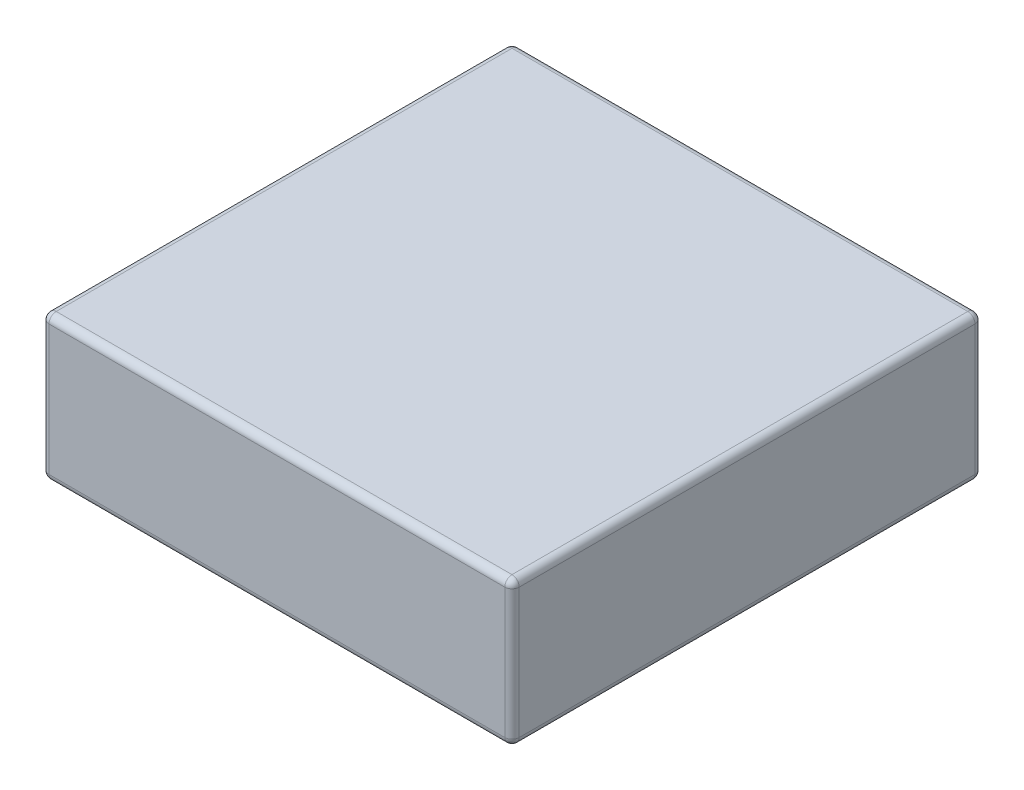
from build123d import *

# Parameters (mm, degrees)
SKETCH1_W           = 65
SKETCH1_H           = 65
BOSS_EXTRUDE1_DEPTH = 20
FILLET1_R           = 1
BOSS_EXTRUDE2_DEPTH = 2


with BuildPart() as part:
    # Sketch1 → Boss-Extrude1 (new body)
    with BuildSketch(Plane(origin=(0, 0, 0), x_dir=(1, 0, 0), z_dir=(0, 1, 0))):
        with Locations((32.5, 32.5)):
            Rectangle(SKETCH1_W, SKETCH1_H)
    extrude(amount=BOSS_EXTRUDE1_DEPTH)

    # Fillet1
    fillet1_edges = [part.edges().sort_by_distance(p)[0] for p in [
        (65, 20, -32.5),
        (32.5, 20, -65),
        (0, 20, -32.5),
        (32.5, 0, -65),
        (65, 0, -32.5),
        (32.5, 0, 0),
        (0, 0, -32.5),
        (0, 10, -65),
        (65, 10, -65),
        (65, 10, 0),
        (0, 10, 0),
        (32.5, 20, 0),
    ]]
    fillet(fillet1_edges, radius=FILLET1_R)

    # Sketch5 → Boss-Extrude2 (add)
    with BuildSketch(Plane(origin=(0, 20, 0), x_dir=(1, 0, 0), z_dir=(0, 1, 0))):
        Polygon((19.685637492, 45.314362508), (24.766822527, 50.395547542), (25.276108448, 49.886261621), (20.194923413, 44.805076587), align=None)
        with BuildLine():
            Line((24.270811136, 43.09904656), (24.718807634, 42.493448688))
            add(Edge.make_bspline(
                [(24.718807634, 42.493448688), (24.65944603, 42.457112102), (24.543657841, 42.386235522), (24.36613492, 42.296211036), (24.192297686, 42.219040325), (24.01995098, 42.159212632), (23.849730523, 42.114752837), (23.681690942, 42.086719988), (23.516089318, 42.075383185), (23.353313359, 42.077400194), (23.19429728, 42.097465643), (23.038449433, 42.128495622), (22.887328161, 42.177860051), (22.740286195, 42.240265036), (22.597438103, 42.3173153), (22.45826992, 42.40727332), (22.32545788, 42.515129055), (22.241429087, 42.594556655), (22.198644924, 42.63499807)],
                knots=[0, 0, 0, 0, 0.000208722, 0.000407124, 0.000596633, 0.000778925, 0.00095377, 0.001123861, 0.001289171, 0.001451177, 0.001611365, 0.001769344, 0.001927175, 0.002087363, 0.002247969, 0.002413511, 0.002583753, 0.002760349, 0.002760349, 0.002760349, 0.002760349], degree=3))
            add(Edge.make_bspline(
                [(22.198644924, 42.63499807), (22.147701284, 42.688346884), (22.04765429, 42.793117339), (21.922554095, 42.967231051), (21.817569235, 43.147019722), (21.73659792, 43.335189786), (21.679785512, 43.530848968), (21.644085884, 43.733421879), (21.633386128, 43.943953589), (21.643285872, 44.161113728), (21.677814894, 44.38377928), (21.742580127, 44.606907144), (21.828375675, 44.832560204), (21.944279573, 45.056953333), (22.083016879, 45.284675208), (22.25070644, 45.510705787), (22.440615653, 45.740739094), (22.58325937, 45.886785575), (22.656856326, 45.962138185)],
                knots=[0, 0, 0, 0, 0.000221059, 0.000434133, 0.00064138, 0.000844681, 0.001046936, 0.001251338, 0.00146034, 0.001678012, 0.001902569, 0.002134488, 0.002373782, 0.002625691, 0.002890982, 0.003172935, 0.003469264, 0.003785121, 0.003785121, 0.003785121, 0.003785121], degree=3))
            add(Edge.make_bspline(
                [(22.656856326, 45.962138185), (22.735304815, 46.037955999), (22.88748258, 46.185030666), (23.123303486, 46.384632603), (23.357638034, 46.557100392), (23.590677334, 46.702822596), (23.821840648, 46.822078206), (24.051852, 46.914709279), (24.280409589, 46.981983021), (24.506932694, 47.018796963), (24.727384439, 47.03431778), (24.940233058, 47.025482357), (25.144352505, 46.994971105), (25.340085808, 46.942519294), (25.526286742, 46.866215225), (25.702710621, 46.766561684), (25.872394562, 46.647715855), (25.973496188, 46.551133092), (26.024856056, 46.502068817)],
                knots=[0, 0, 0, 0, 0.000327232, 0.000634778, 0.000926067, 0.001199391, 0.001458489, 0.001705352, 0.00194228, 0.002171628, 0.00239246, 0.002604236, 0.002809376, 0.003010444, 0.003210705, 0.003411263, 0.003617372, 0.003830186, 0.003830186, 0.003830186, 0.003830186], degree=3))
            add(Edge.make_bspline(
                [(26.024856056, 46.502068817), (26.071398533, 46.453066353), (26.163167054, 46.356447435), (26.277023523, 46.193668973), (26.37086823, 46.023021925), (26.443461426, 45.842869536), (26.493233934, 45.653122307), (26.520175644, 45.45373442), (26.527595943, 45.24544748), (26.512535805, 45.029344415), (26.475308317, 44.807364737), (26.409425794, 44.583426164), (26.320915695, 44.357268318), (26.201043695, 44.132062546), (26.060507567, 43.902626648), (25.89079672, 43.673437755), (25.696655056, 43.442073581), (25.552080753, 43.293670825), (25.477629063, 43.21724759)],
                knots=[0, 0, 0, 0, 0.000202508, 0.000399288, 0.000593897, 0.000785751, 0.000980426, 0.001180814, 0.001388159, 0.001604624, 0.001829655, 0.002061973, 0.002303688, 0.00255693, 0.002826235, 0.003110228, 0.003411606, 0.003731589, 0.003731589, 0.003731589, 0.003731589], degree=3))
            Line((25.477629063, 43.21724759), (25.308353514, 43.053809128))
            Line((25.308353514, 43.053809128), (23.055237576, 45.306925066))
            add(Edge.make_bspline(
                [(23.055237576, 45.306925066), (23.008428941, 45.253428574), (22.917532008, 45.149544603), (22.794995519, 44.99005008), (22.687606361, 44.834345409), (22.598042408, 44.680102339), (22.523988968, 44.528378877), (22.46893383, 44.377973841), (22.428484602, 44.230679765), (22.404672414, 44.086328807), (22.398574981, 43.946465898), (22.401417614, 43.812435439), (22.421043899, 43.684765665), (22.452728022, 43.563194715), (22.498625025, 43.448182852), (22.557092061, 43.339791827), (22.629175623, 43.237817936), (22.686267844, 43.176729605), (22.715227205, 43.145743263)],
                knots=[0, 0, 0, 0, 0.000213204, 0.000414017, 0.000603036, 0.00078024, 0.000948633, 0.00110884, 0.001259993, 0.001406336, 0.001546616, 0.001679481, 0.001807848, 0.00193315, 0.002055633, 0.002178385, 0.002301882, 0.002429006, 0.002429006, 0.002429006, 0.002429006], degree=3))
            add(Edge.make_bspline(
                [(22.715227205, 43.145743263), (22.763714327, 43.101268255), (22.858414682, 43.014403973), (23.025956737, 42.922340751), (23.204141766, 42.861085255), (23.396323147, 42.841646968), (23.600048933, 42.851176309), (23.814991722, 42.901604999), (24.042730565, 42.981679607), (24.192378727, 43.05868638), (24.270811136, 43.09904656)],
                knots=[0, 0, 0, 0, 0.000196748, 0.000384268, 0.000568853, 0.000758368, 0.000960006, 0.001178117, 0.001418122, 0.001682448, 0.001682448, 0.001682448, 0.001682448], degree=3))
        make_face()
        with BuildLine():
            Line((23.598086753, 45.788484819), (25.282086618, 44.104484954))
            add(Edge.make_bspline(
                [(25.282086618, 44.104484954), (25.317456152, 44.146521608), (25.385900663, 44.227867836), (25.479775603, 44.350787831), (25.561877228, 44.470464632), (25.632124497, 44.587358235), (25.691145975, 44.700570312), (25.736058611, 44.811350606), (25.773087872, 44.917520401), (25.786377298, 44.989073722), (25.792831811, 45.023826301)],
                knots=[0, 0, 0, 0, 0.000164794, 0.000318898, 0.0004638, 0.000599943, 0.000727861, 0.000846287, 0.000958423, 0.001064318, 0.001064318, 0.001064318, 0.001064318], degree=3))
            add(Edge.make_bspline(
                [(25.792831811, 45.023826301), (25.799813725, 45.071878299), (25.813377134, 45.165226467), (25.814257222, 45.30339848), (25.801182934, 45.435020893), (25.774145727, 45.560903067), (25.729739188, 45.679965001), (25.670458197, 45.791928238), (25.597330146, 45.898165534), (25.538293331, 45.961856188), (25.508273775, 45.994242168)],
                knots=[0, 0, 0, 0, 0.000145525, 0.000282705, 0.000413242, 0.000541766, 0.000667814, 0.000793141, 0.000921059, 0.001053395, 0.001053395, 0.001053395, 0.001053395], degree=3))
            add(Edge.make_bspline(
                [(25.508273775, 45.994242168), (25.479202656, 46.021698757), (25.422234743, 46.075502829), (25.327077988, 46.143572618), (25.226022071, 46.198991516), (25.119469498, 46.243146809), (25.006665555, 46.273929901), (24.888728253, 46.292595438), (24.764604833, 46.299684032), (24.636059667, 46.29554037), (24.504591069, 46.27783771), (24.372662252, 46.247016845), (24.241600945, 46.202755032), (24.110298143, 46.147206738), (23.980677113, 46.076811617), (23.852388098, 45.992570612), (23.722553615, 45.897996438), (23.640333437, 45.825655378), (23.598086753, 45.788484819)],
                knots=[0, 0, 0, 0, 0.000119856, 0.00023487, 0.00034982, 0.000464991, 0.000580052, 0.000699766, 0.000822561, 0.00095251, 0.001085007, 0.001219869, 0.001358308, 0.001499526, 0.001647086, 0.001800087, 0.001959736, 0.002128463, 0.002128463, 0.002128463, 0.002128463], degree=3))
        make_face(mode=Mode.SUBTRACT)
        with BuildLine():
            Line((24.256928886, 40.743071114), (27.937212819, 44.423355048))
            Line((27.937212819, 44.423355048), (28.396883493, 43.963684374))
            Line((28.396883493, 43.963684374), (27.874464124, 43.441265005))
            add(Edge.make_bspline(
                [(27.874464124, 43.441265005), (27.950920243, 43.461674048), (28.098922361, 43.501181437), (28.321702162, 43.527286092), (28.534408586, 43.525711262), (28.736967661, 43.492266462), (28.930507375, 43.434748033), (29.112252205, 43.344942514), (29.285821773, 43.23105084), (29.388065649, 43.135461808), (29.440262959, 43.086661914)],
                knots=[0, 0, 0, 0, 0.00023714, 0.00045905, 0.000670664, 0.000873146, 0.001073023, 0.001274043, 0.001479241, 0.001693257, 0.001693257, 0.001693257, 0.001693257], degree=3))
            add(Edge.make_bspline(
                [(29.440262959, 43.086661914), (29.479237571, 43.045701744), (29.555948444, 42.965082845), (29.651727199, 42.830729926), (29.733688037, 42.691079746), (29.796795775, 42.54476151), (29.843933405, 42.396078746), (29.872725772, 42.248190754), (29.887408477, 42.10287992), (29.880498237, 41.958770633), (29.857841761, 41.814281782), (29.811728374, 41.668054182), (29.749403454, 41.518247208), (29.680906385, 41.391900736), (29.614240997, 41.286817058), (29.55205399, 41.200752274), (29.481461369, 41.107516401), (29.397994108, 41.009652562), (29.307522476, 40.903718375), (29.205603934, 40.792000351), (29.093727999, 40.674235372), (29.014326282, 40.594545181), (28.973295925, 40.553365757)],
                knots=[0, 0, 0, 0, 0.000169426, 0.00033347, 0.000493658, 0.000654423, 0.000810422, 0.00096067, 0.001105734, 0.001247403, 0.001392305, 0.001543261, 0.001706138, 0.001878505, 0.001973638, 0.002079322, 0.002196945, 0.00232437, 0.002465082, 0.002614877, 0.002777963, 0.00295235, 0.00295235, 0.00295235, 0.00295235], degree=3))
            Line((28.973295925, 40.553365757), (26.709965084, 38.290034916))
            Line((26.709965084, 38.290034916), (26.197760619, 38.802239381))
            Line((26.197760619, 38.802239381), (28.436283837, 41.040762598))
            add(Edge.make_bspline(
                [(28.436283837, 41.040762598), (28.498834303, 41.104732657), (28.614954251, 41.223487965), (28.764812047, 41.398480511), (28.879101321, 41.554577542), (28.960654173, 41.695654959), (29.012514868, 41.828209488), (29.040075072, 41.956841821), (29.050277675, 42.084305362), (29.036279506, 42.209999528), (29.003709911, 42.331703897), (28.954677983, 42.448518613), (28.882691104, 42.556276666), (28.823880395, 42.620443943), (28.793805472, 42.653258136)],
                knots=[0, 0, 0, 0, 0.000268355, 0.00049818, 0.00069055, 0.000848023, 0.00098569, 0.001115639, 0.001241442, 0.001367624, 0.001492926, 0.001618432, 0.001745925, 0.001879358, 0.001879358, 0.001879358, 0.001879358], degree=3))
            add(Edge.make_bspline(
                [(28.793805472, 42.653258136), (28.763187059, 42.682046242), (28.702932566, 42.738698845), (28.605315182, 42.81236554), (28.502003168, 42.870205812), (28.396735111, 42.918527741), (28.285997777, 42.950250802), (28.171905723, 42.969342191), (28.053919522, 42.97490495), (27.931901325, 42.967925543), (27.804732482, 42.94415941), (27.673021679, 42.901129229), (27.536350163, 42.838100954), (27.393143948, 42.75815232), (27.246606826, 42.656239788), (27.093618898, 42.536931702), (26.935494109, 42.398840319), (26.83109022, 42.297220606), (26.777091595, 42.244661982)],
                knots=[0, 0, 0, 0, 0.000126039, 0.000248035, 0.000365685, 0.000480662, 0.000594719, 0.000710112, 0.000827, 0.000948339, 0.00107599, 0.001213974, 0.001362884, 0.001526876, 0.001705373, 0.001897736, 0.002108731, 0.002334768, 0.002334768, 0.002334768, 0.002334768], degree=3))
            Line((26.777091595, 42.244661982), (24.766214807, 40.233785193))
            Line((24.766214807, 40.233785193), (24.256928886, 40.743071114))
        make_face()
        with BuildLine():
            Line((28.397593963, 38.800069639), (28.998814018, 38.391473485))
            add(Edge.make_bspline(
                [(28.998814018, 38.391473485), (28.971522035, 38.355862259), (28.918530346, 38.286717449), (28.850053452, 38.179416628), (28.791547054, 38.074906972), (28.743199129, 37.971463994), (28.709297745, 37.868277663), (28.683201074, 37.767042009), (28.670469797, 37.667078287), (28.666043136, 37.536705125), (28.688594893, 37.374482586), (28.758670326, 37.187340011), (28.866105164, 37.006369777), (28.964064917, 36.900834271), (29.01486601, 36.846104458)],
                knots=[0, 0, 0, 0, 0.000134546, 0.000261243, 0.000381436, 0.000493752, 0.00060312, 0.00070682, 0.000806916, 0.000904731, 0.001097692, 0.00129343, 0.001500898, 0.001724391, 0.001724391, 0.001724391, 0.001724391], degree=3))
            add(Edge.make_bspline(
                [(29.01486601, 36.846104458), (29.069441835, 36.795835111), (29.172990452, 36.700457326), (29.342679441, 36.588820454), (29.516720057, 36.519990136), (29.690805894, 36.489543092), (29.859716906, 36.498403237), (30.01876995, 36.541915162), (30.16708271, 36.618757165), (30.250415812, 36.693776173), (30.293188265, 36.732281244)],
                knots=[0, 0, 0, 0, 0.000222389, 0.000421947, 0.000605404, 0.000780054, 0.000948098, 0.001108466, 0.00127165, 0.001443733, 0.001443733, 0.001443733, 0.001443733], degree=3))
            add(Edge.make_bspline(
                [(30.293188265, 36.732281244), (30.326160082, 36.768383514), (30.389471047, 36.83770543), (30.452583476, 36.961547014), (30.483616436, 37.093216642), (30.478287487, 37.18210217), (30.475597262, 37.226974445)],
                knots=[0, 0, 0, 0, 0.000146109, 0.000280553, 0.000412243, 0.000546504, 0.000546504, 0.000546504, 0.000546504], degree=3))
            add(Edge.make_bspline(
                [(30.475597262, 37.226974445), (30.472436749, 37.244538199), (30.465345915, 37.283943725), (30.447476422, 37.347936753), (30.420458765, 37.422708398), (30.385593212, 37.508478052), (30.341249593, 37.604367281), (30.290137516, 37.711619684), (30.229915462, 37.829400163), (30.187187713, 37.911880955), (30.164772331, 37.955151163)],
                knots=[0, 0, 0, 0, 5.3518e-05, 0.000120071, 0.000198993, 0.000291941, 0.000397735, 0.000515873, 0.000648354, 0.000794551, 0.000794551, 0.000794551, 0.000794551], degree=3))
            add(Edge.make_bspline(
                [(30.164772331, 37.955151163), (30.132090575, 38.017850384), (30.069445542, 38.138033488), (29.980891546, 38.311481042), (29.906007385, 38.472488345), (29.838085929, 38.617626828), (29.782172165, 38.748899705), (29.738643504, 38.866657164), (29.702585494, 38.969246159), (29.671389798, 39.087584192), (29.651000577, 39.227233321), (29.645328094, 39.392084984), (29.66561401, 39.556940667), (29.706464713, 39.720228472), (29.768908951, 39.881076669), (29.855399766, 40.034931713), (29.960088954, 40.184138289), (30.045337829, 40.273512063), (30.088890188, 40.31917177)],
                knots=[0, 0, 0, 0, 0.000212122, 0.0004066, 0.000584152, 0.000744778, 0.000887339, 0.001012019, 0.001121387, 0.001213414, 0.001378724, 0.00154368, 0.001706766, 0.001875235, 0.002047583, 0.002222629, 0.002403632, 0.002592691, 0.002592691, 0.002592691, 0.002592691], degree=3))
            add(Edge.make_bspline(
                [(30.088890188, 40.31917177), (30.128032615, 40.356994116), (30.204637433, 40.431015431), (30.329853162, 40.525425421), (30.457257226, 40.606915946), (30.589343694, 40.672832991), (30.725094725, 40.72443303), (30.865240049, 40.759511449), (31.009011182, 40.779880625), (31.15574204, 40.785985308), (31.303476447, 40.77552129), (31.450575101, 40.749648993), (31.595190228, 40.704455907), (31.739136944, 40.646670282), (31.880006672, 40.570079835), (32.016772837, 40.474711543), (32.155421954, 40.367907691), (32.241136901, 40.284569229), (32.285094518, 40.241830356)],
                knots=[0, 0, 0, 0, 0.000163152, 0.0003193, 0.000469499, 0.000616336, 0.000761341, 0.000904327, 0.001048787, 0.001196289, 0.001344029, 0.001492302, 0.001643257, 0.00179772, 0.001957041, 0.002122988, 0.002297565, 0.00248134, 0.00248134, 0.00248134, 0.00248134], degree=3))
            add(Edge.make_bspline(
                [(32.285094518, 40.241830356), (32.337852306, 40.185948728), (32.440535985, 40.077185051), (32.571187106, 39.900500906), (32.677552367, 39.719402205), (32.756128791, 39.533579644), (32.810566231, 39.348425774), (32.840497313, 39.166043217), (32.845606599, 38.987690971), (32.823451513, 38.810732341), (32.769345652, 38.630694319), (32.684733386, 38.442518618), (32.568144059, 38.242589122), (32.471765986, 38.111840057), (32.420806812, 38.042707482)],
                knots=[0, 0, 0, 0, 0.000230385, 0.000448403, 0.000657645, 0.000859029, 0.001052062, 0.00123535, 0.001411976, 0.001585556, 0.001767965, 0.001973769, 0.002203283, 0.002460794, 0.002460794, 0.002460794, 0.002460794], degree=3))
            Line((32.420806812, 38.042707482), (31.838557292, 38.458599996))
            add(Edge.make_bspline(
                [(31.838557292, 38.458599996), (31.879401728, 38.51282359), (31.956839937, 38.615627749), (32.038231596, 38.782456396), (32.088056737, 38.946173696), (32.097929335, 39.108657145), (32.074764551, 39.268501518), (32.011217909, 39.423461233), (31.917510187, 39.578116516), (31.831252687, 39.668893474), (31.7860235, 39.716492443)],
                knots=[0, 0, 0, 0, 0.000203232, 0.000385314, 0.00055389, 0.000713278, 0.000869713, 0.001034204, 0.001212402, 0.001408846, 0.001408846, 0.001408846, 0.001408846], degree=3))
            add(Edge.make_bspline(
                [(31.7860235, 39.716492443), (31.732905563, 39.767245769), (31.632896426, 39.862802875), (31.471323107, 39.973278235), (31.314661986, 40.048901469), (31.161343523, 40.083293574), (31.016122049, 40.084183944), (30.881109182, 40.052442759), (30.756185721, 39.992096689), (30.687338587, 39.930412026), (30.652169172, 39.89890144)],
                knots=[0, 0, 0, 0, 0.000220079, 0.00041436, 0.00058477, 0.000738777, 0.000881786, 0.001016648, 0.001151739, 0.001292814, 0.001292814, 0.001292814, 0.001292814], degree=3))
            add(Edge.make_bspline(
                [(30.652169172, 39.89890144), (30.620980875, 39.864787494), (30.56085833, 39.799025094), (30.505240554, 39.679362067), (30.475944511, 39.552357767), (30.483423349, 39.466101156), (30.487271438, 39.421719503)],
                knots=[0, 0, 0, 0, 0.000137892, 0.000265817, 0.000391179, 0.000524045, 0.000524045, 0.000524045, 0.000524045], degree=3))
            add(Edge.make_bspline(
                [(30.487271438, 39.421719503), (30.490395657, 39.405599282), (30.497591674, 39.368469557), (30.51761967, 39.306581144), (30.547778094, 39.231420948), (30.583137156, 39.140516056), (30.631435245, 39.037519127), (30.684545951, 38.91846373), (30.749096811, 38.786514203), (30.795575431, 38.693983064), (30.81998545, 38.645386809)],
                knots=[0, 0, 0, 0, 4.9227e-05, 0.000113386, 0.000194687, 0.00029224, 0.000405885, 0.000535834, 0.000683336, 0.000846488, 0.000846488, 0.000846488, 0.000846488], degree=3))
            add(Edge.make_bspline(
                [(30.81998545, 38.645386809), (30.854241274, 38.578364373), (30.919783653, 38.450128957), (31.010409734, 38.264835791), (31.088680835, 38.096258791), (31.156781293, 37.94468116), (31.213492505, 37.810005253), (31.259398025, 37.691477566), (31.293388142, 37.589773918), (31.322924098, 37.476840305), (31.342727876, 37.346038471), (31.346133978, 37.190906285), (31.326672281, 37.0352135), (31.285351421, 36.879683127), (31.221973226, 36.725730455), (31.136256285, 36.574338558), (31.027588952, 36.425818198), (30.94073455, 36.334418329), (30.895867593, 36.28720329)],
                knots=[0, 0, 0, 0, 0.000225806, 0.000432038, 0.000618757, 0.00078337, 0.000930533, 0.001057094, 0.001164616, 0.001252039, 0.001407031, 0.001560282, 0.001716124, 0.001876112, 0.002041687, 0.002214184, 0.002396896, 0.002592139, 0.002592139, 0.002592139, 0.002592139], degree=3))
            add(Edge.make_bspline(
                [(30.895867593, 36.28720329), (30.851817853, 36.245074856), (30.765912472, 36.162916386), (30.627629082, 36.055078362), (30.484151508, 35.966369126), (30.337376295, 35.892498955), (30.186503854, 35.834808362), (30.030651537, 35.79571987), (29.870826238, 35.771824325), (29.707857867, 35.766324916), (29.544441736, 35.777811936), (29.382528905, 35.807402037), (29.223111606, 35.854369959), (29.065755909, 35.918731104), (28.912773946, 36.003128348), (28.761056762, 36.103050362), (28.612124467, 36.221279404), (28.518484897, 36.311216194), (28.470557562, 36.357248345)],
                knots=[0, 0, 0, 0, 0.000182782, 0.00035646, 0.00052491, 0.000688061, 0.00084878, 0.001008402, 0.001169167, 0.00133271, 0.001496565, 0.001659716, 0.00182549, 0.001994318, 0.002168663, 0.002348769, 0.002538839, 0.002738119, 0.002738119, 0.002738119, 0.002738119], degree=3))
            add(Edge.make_bspline(
                [(28.470557562, 36.357248345), (28.427696267, 36.402468293), (28.343913067, 36.490862078), (28.230344781, 36.628742225), (28.137296187, 36.771840292), (28.057674052, 36.91473211), (27.993735635, 37.059955561), (27.948727467, 37.208502847), (27.91867848, 37.359049844), (27.908110126, 37.511824801), (27.910033188, 37.666380447), (27.931374691, 37.822782558), (27.968283906, 37.981457637), (28.021195898, 38.142021663), (28.089925891, 38.304855974), (28.177404962, 38.468379919), (28.279416872, 38.635292974), (28.357473233, 38.744128509), (28.397593963, 38.800069639)],
                knots=[0, 0, 0, 0, 0.000186906, 0.000365356, 0.000534939, 0.000698221, 0.000855728, 0.001009901, 0.001163013, 0.001315226, 0.001468477, 0.00162595, 0.001787719, 0.001956616, 0.002132518, 0.002317247, 0.002512462, 0.002718922, 0.002718922, 0.002718922, 0.002718922], degree=3))
        make_face()
        with BuildLine():
            Line((32.194011935, 32.805988065), (35.389817571, 36.001793702))
            Line((35.389817571, 36.001793702), (34.935983985, 36.455627287))
            Line((34.935983985, 36.455627287), (35.420462283, 36.940105585))
            Line((35.420462283, 36.940105585), (35.874295868, 36.486271999))
            Line((35.874295868, 36.486271999), (36.266840031, 36.878816162))
            add(Edge.make_bspline(
                [(36.266840031, 36.878816162), (36.335517636, 36.945443651), (36.46397807, 37.070069373), (36.656925909, 37.230565412), (36.833848513, 37.353613251), (36.999247715, 37.439264272), (37.156364433, 37.492449427), (37.310202624, 37.517178985), (37.462874394, 37.519330465), (37.614658158, 37.495309962), (37.765426607, 37.446344255), (37.913452379, 37.370979935), (38.058218961, 37.268451948), (38.146891462, 37.184969378), (38.193079045, 37.141485118)],
                knots=[0, 0, 0, 0, 0.000286976, 0.000536785, 0.00075211, 0.000932234, 0.001093746, 0.001247524, 0.001397836, 0.001549944, 0.001706386, 0.001871497, 0.002046396, 0.002236539, 0.002236539, 0.002236539, 0.002236539], degree=3))
            add(Edge.make_bspline(
                [(38.193079045, 37.141485118), (38.229731778, 37.103635711), (38.305147448, 37.025757799), (38.408411527, 36.894542479), (38.513431492, 36.753923442), (38.576634578, 36.652160706), (38.608971559, 36.600095213)],
                knots=[0, 0, 0, 0, 0.000157959, 0.000325012, 0.000500429, 0.000684204, 0.000684204, 0.000684204, 0.000684204], degree=3))
            Line((38.608971559, 36.600095213), (37.99024024, 36.13312818))
            add(Edge.make_bspline(
                [(37.99024024, 36.13312818), (37.94856809, 36.19474545), (37.868033833, 36.313825004), (37.769353, 36.418330984), (37.721734195, 36.468760735)],
                knots=[0, 0, 0, 0, 0.000222734, 0.000430448, 0.000430448, 0.000430448, 0.000430448], degree=3))
            add(Edge.make_bspline(
                [(37.721734195, 36.468760735), (37.684984469, 36.503325988), (37.616380818, 36.567851707), (37.501351347, 36.6373372), (37.38710354, 36.676508314), (37.269527367, 36.681322992), (37.146066829, 36.648969031), (37.015877585, 36.572935867), (36.868735235, 36.464180863), (36.773005584, 36.370905363), (36.720673617, 36.319914993)],
                knots=[0, 0, 0, 0, 0.000151005, 0.000281893, 0.00040003, 0.000509563, 0.000629898, 0.000777458, 0.000958995, 0.001177905, 0.001177905, 0.001177905, 0.001177905], degree=3))
            Line((36.720673617, 36.319914993), (36.380663246, 35.979904622))
            Line((36.380663246, 35.979904622), (36.970209125, 35.390358742))
            Line((36.970209125, 35.390358742), (36.485730828, 34.905880445))
            Line((36.485730828, 34.905880445), (35.896184948, 35.495426324))
            Line((35.896184948, 35.495426324), (32.700379312, 32.299620688))
            Line((32.700379312, 32.299620688), (32.194011935, 32.805988065))
        make_face()
        Polygon((38.063745009, 35.662701431), (38.781706824, 36.380663246), (39.290992745, 35.871377324), (38.57303093, 35.15341551), align=None)
        Polygon((33.700521789, 31.299478211), (37.380805723, 34.979762145), (37.890091644, 34.470476224), (34.20980771, 30.79019229), align=None)
        Polygon((35.006711293, 29.993288707), (40.087896328, 35.074473741), (40.597182249, 34.56518782), (35.515997215, 29.484002785), align=None)
        with BuildLine():
            Line((38.03921955, 28.075664242), (37.557659797, 27.456932923))
            add(Edge.make_bspline(
                [(37.557659797, 27.456932923), (37.515050023, 27.482745795), (37.43238392, 27.532824672), (37.31718147, 27.612941746), (37.213488023, 27.695009592), (37.151582133, 27.75368446), (37.121337475, 27.782350574)],
                knots=[0, 0, 0, 0, 0.000149424, 0.000289894, 0.000420708, 0.00054567, 0.00054567, 0.00054567, 0.00054567], degree=3))
            add(Edge.make_bspline(
                [(37.121337475, 27.782350574), (37.080520821, 27.826284363), (37.00266627, 27.910084602), (36.905335621, 28.043375934), (36.837471953, 28.179367766), (36.793839433, 28.314754345), (36.776062632, 28.449207905), (36.781793895, 28.580641418), (36.810848404, 28.708565298), (36.851754189, 28.814304299), (36.903226494, 28.900217385), (36.952401532, 28.97672984), (37.017456151, 29.060621154), (37.095235374, 29.154191678), (37.185990582, 29.257605167), (37.289197155, 29.371823644), (37.408036732, 29.493393567), (37.491018667, 29.578231476), (37.534311445, 29.622492541)],
                knots=[0, 0, 0, 0, 0.00017984, 0.000343031, 0.00049313, 0.000633895, 0.000767839, 0.000897845, 0.001026369, 0.001159962, 0.001235802, 0.001326465, 0.001432701, 0.001553961, 0.001691513, 0.00184543, 0.002015715, 0.002201461, 0.002201461, 0.002201461, 0.002201461], degree=3))
            Line((37.534311445, 29.622492541), (39.651715088, 31.739896184))
            Line((39.651715088, 31.739896184), (39.276682189, 32.114929083))
            Line((39.276682189, 32.114929083), (39.761160487, 32.599407381))
            Line((39.761160487, 32.599407381), (40.136193386, 32.224374482))
            Line((40.136193386, 32.224374482), (41.048238373, 33.136419469))
            Line((41.048238373, 33.136419469), (41.931097921, 33.000707175))
            Line((41.931097921, 33.000707175), (40.645479307, 31.715088561))
            Line((40.645479307, 31.715088561), (41.162061588, 31.19850628))
            Line((41.162061588, 31.19850628), (40.67758329, 30.714027982))
            Line((40.67758329, 30.714027982), (40.161001009, 31.230610263))
            Line((40.161001009, 31.230610263), (38.008574839, 29.078184093))
            add(Edge.make_bspline(
                [(38.008574839, 29.078184093), (37.963565468, 29.032602902), (37.882150668, 28.950153768), (37.782632017, 28.831135525), (37.70657419, 28.737041742), (37.67976807, 28.67403323), (37.668564467, 28.647698859)],
                knots=[0, 0, 0, 0, 0.000191971, 0.000347244, 0.000466334, 0.000551848, 0.000551848, 0.000551848, 0.000551848], degree=3))
            add(Edge.make_bspline(
                [(37.668564467, 28.647698859), (37.661368448, 28.616170398), (37.647174638, 28.553981992), (37.667335502, 28.456091259), (37.713318119, 28.360307296), (37.764109452, 28.305966729), (37.791143314, 28.277043776)],
                knots=[0, 0, 0, 0, 9.5969e-05, 0.000189294, 0.000293066, 0.00041115, 0.00041115, 0.00041115, 0.00041115], degree=3))
            add(Edge.make_bspline(
                [(37.791143314, 28.277043776), (37.825644347, 28.245276519), (37.904125739, 28.173013796), (37.99070257, 28.110625921), (38.03921955, 28.075664242)],
                knots=[0, 0, 0, 0, 0.000140576, 0.000319775, 0.000319775, 0.000319775, 0.000319775], degree=3))
        make_face()
        with BuildLine():
            Line((41.242862717, 26.126994978), (41.690859215, 25.521397106))
            add(Edge.make_bspline(
                [(41.690859215, 25.521397106), (41.631497611, 25.485060521), (41.515709422, 25.414183941), (41.338186502, 25.324159455), (41.164349268, 25.246988743), (40.992002561, 25.18716105), (40.821782105, 25.142701255), (40.653742523, 25.114668406), (40.4881409, 25.103331603), (40.32536494, 25.105348613), (40.166348862, 25.125414061), (40.010501015, 25.156444041), (39.859379743, 25.20580847), (39.712337777, 25.268213455), (39.569489684, 25.345263718), (39.430321501, 25.435221738), (39.297509461, 25.543077474), (39.213480668, 25.622505073), (39.170696506, 25.662946489)],
                knots=[0, 0, 0, 0, 0.000208722, 0.000407124, 0.000596633, 0.000778925, 0.00095377, 0.001123861, 0.001289171, 0.001451177, 0.001611365, 0.001769344, 0.001927175, 0.002087363, 0.002247969, 0.002413511, 0.002583753, 0.002760349, 0.002760349, 0.002760349, 0.002760349], degree=3))
            add(Edge.make_bspline(
                [(39.170696506, 25.662946489), (39.119752865, 25.716295302), (39.019705871, 25.821065758), (38.894605676, 25.99517947), (38.789620817, 26.17496814), (38.708649501, 26.363138204), (38.651837093, 26.558797387), (38.616137466, 26.761370297), (38.605437709, 26.971902007), (38.615337453, 27.189062146), (38.649866476, 27.411727698), (38.714631708, 27.634855562), (38.800427257, 27.860508623), (38.916331154, 28.084901752), (39.055068461, 28.312623626), (39.222758022, 28.538654205), (39.412667234, 28.768687513), (39.555310952, 28.914733994), (39.628907907, 28.990086603)],
                knots=[0, 0, 0, 0, 0.000221059, 0.000434133, 0.00064138, 0.000844681, 0.001046936, 0.001251338, 0.00146034, 0.001678012, 0.001902569, 0.002134488, 0.002373782, 0.002625691, 0.002890982, 0.003172935, 0.003469264, 0.003785121, 0.003785121, 0.003785121, 0.003785121], degree=3))
            add(Edge.make_bspline(
                [(39.628907907, 28.990086603), (39.707356397, 29.065904417), (39.859534162, 29.212979085), (40.095355068, 29.412581022), (40.329689615, 29.58504881), (40.562728915, 29.730771014), (40.793892229, 29.850026625), (41.023903582, 29.942657697), (41.252461171, 30.00993144), (41.478984276, 30.046745381), (41.69943602, 30.062266198), (41.91228464, 30.053430775), (42.116404087, 30.022919524), (42.312137389, 29.970467712), (42.498338323, 29.894163644), (42.674762203, 29.794510102), (42.844446144, 29.675664273), (42.94554777, 29.57908151), (42.996907637, 29.530017236)],
                knots=[0, 0, 0, 0, 0.000327232, 0.000634778, 0.000926067, 0.001199391, 0.001458489, 0.001705352, 0.00194228, 0.002171628, 0.00239246, 0.002604236, 0.002809376, 0.003010444, 0.003210705, 0.003411263, 0.003617372, 0.003830186, 0.003830186, 0.003830186, 0.003830186], degree=3))
            add(Edge.make_bspline(
                [(42.996907637, 29.530017236), (43.043450114, 29.481014771), (43.135218636, 29.384395854), (43.249075105, 29.221617392), (43.342919812, 29.050970344), (43.415513007, 28.870817954), (43.465285516, 28.681070726), (43.492227225, 28.481682839), (43.499647524, 28.273395898), (43.484587386, 28.057292834), (43.447359898, 27.835313155), (43.381477375, 27.611374582), (43.292967277, 27.385216736), (43.173095277, 27.160010965), (43.032559148, 26.930575066), (42.862848302, 26.701386173), (42.668706637, 26.470022), (42.524132335, 26.321619244), (42.449680645, 26.245196009)],
                knots=[0, 0, 0, 0, 0.000202508, 0.000399288, 0.000593897, 0.000785751, 0.000980426, 0.001180814, 0.001388159, 0.001604624, 0.001829655, 0.002061973, 0.002303688, 0.00255693, 0.002826235, 0.003110228, 0.003411606, 0.003731589, 0.003731589, 0.003731589, 0.003731589], degree=3))
            Line((42.449680645, 26.245196009), (42.280405095, 26.081757547))
            Line((42.280405095, 26.081757547), (40.027289158, 28.334873484))
            add(Edge.make_bspline(
                [(40.027289158, 28.334873484), (39.980480522, 28.281376993), (39.889583589, 28.177493021), (39.767047101, 28.017998498), (39.659657943, 27.862293828), (39.570093989, 27.708050757), (39.496040549, 27.556327295), (39.440985411, 27.40592226), (39.400536183, 27.258628183), (39.376723995, 27.114277225), (39.370626562, 26.974414317), (39.373469195, 26.840383858), (39.393095481, 26.712714084), (39.424779604, 26.591143133), (39.470676606, 26.47613127), (39.529143643, 26.367740245), (39.601227205, 26.265766354), (39.658319425, 26.204678024), (39.687278787, 26.173691682)],
                knots=[0, 0, 0, 0, 0.000213204, 0.000414017, 0.000603036, 0.00078024, 0.000948633, 0.00110884, 0.001259993, 0.001406336, 0.001546616, 0.001679481, 0.001807848, 0.00193315, 0.002055633, 0.002178385, 0.002301882, 0.002429006, 0.002429006, 0.002429006, 0.002429006], degree=3))
            add(Edge.make_bspline(
                [(39.687278787, 26.173691682), (39.735765909, 26.129216673), (39.830466263, 26.042352392), (39.998008318, 25.950289169), (40.176193347, 25.889033673), (40.368374729, 25.869595386), (40.572100515, 25.879124727), (40.787043303, 25.929553417), (41.014782146, 26.009628025), (41.164430309, 26.086634798), (41.242862717, 26.126994978)],
                knots=[0, 0, 0, 0, 0.000196748, 0.000384268, 0.000568853, 0.000758368, 0.000960006, 0.001178117, 0.001418122, 0.001682448, 0.001682448, 0.001682448, 0.001682448], degree=3))
        make_face()
        with BuildLine():
            Line((40.570138335, 28.816433237), (42.2541382, 27.132433372))
            add(Edge.make_bspline(
                [(42.2541382, 27.132433372), (42.289507734, 27.174470026), (42.357952245, 27.255816254), (42.451827184, 27.37873625), (42.53392881, 27.49841305), (42.604176078, 27.615306653), (42.663197557, 27.728518731), (42.708110193, 27.839299025), (42.745139454, 27.945468819), (42.75842888, 28.01702214), (42.764883393, 28.05177472)],
                knots=[0, 0, 0, 0, 0.000164794, 0.000318898, 0.0004638, 0.000599943, 0.000727861, 0.000846287, 0.000958423, 0.001064318, 0.001064318, 0.001064318, 0.001064318], degree=3))
            add(Edge.make_bspline(
                [(42.764883393, 28.05177472), (42.771865307, 28.099826718), (42.785428716, 28.193174886), (42.786308804, 28.331346899), (42.773234516, 28.462969311), (42.746197308, 28.588851486), (42.701790769, 28.707913419), (42.642509779, 28.819876656), (42.569381728, 28.926113952), (42.510344912, 28.989804606), (42.480325356, 29.022190587)],
                knots=[0, 0, 0, 0, 0.000145525, 0.000282705, 0.000413242, 0.000541766, 0.000667814, 0.000793141, 0.000921059, 0.001053395, 0.001053395, 0.001053395, 0.001053395], degree=3))
            add(Edge.make_bspline(
                [(42.480325356, 29.022190587), (42.451254238, 29.049647175), (42.394286324, 29.103451247), (42.299129569, 29.171521037), (42.198073652, 29.226939935), (42.091521079, 29.271095227), (41.978717137, 29.30187832), (41.860779835, 29.320543856), (41.736656414, 29.327632451), (41.608111249, 29.323488788), (41.476642651, 29.305786129), (41.344713834, 29.274965264), (41.213652526, 29.23070345), (41.082349725, 29.175155156), (40.952728694, 29.104760036), (40.824439679, 29.020519031), (40.694605197, 28.925944857), (40.612385019, 28.853603796), (40.570138335, 28.816433237)],
                knots=[0, 0, 0, 0, 0.000119856, 0.00023487, 0.00034982, 0.000464991, 0.000580052, 0.000699766, 0.000822561, 0.00095251, 0.001085007, 0.001219869, 0.001358308, 0.001499526, 0.001647086, 0.001800087, 0.001959736, 0.002128463, 0.002128463, 0.002128463, 0.002128463], degree=3))
        make_face(mode=Mode.SUBTRACT)
        with BuildLine():
            Line((41.228980467, 23.771019533), (44.909264401, 27.451303466))
            Line((44.909264401, 27.451303466), (45.368935075, 26.991632793))
            Line((45.368935075, 26.991632793), (44.811493178, 26.434190896))
            add(Edge.make_bspline(
                [(44.811493178, 26.434190896), (44.857082737, 26.451115446), (44.944355433, 26.483514336), (45.072731118, 26.524238854), (45.191321051, 26.559222199), (45.300583308, 26.587819531), (45.401186409, 26.606480476), (45.49213213, 26.620156307), (45.574594504, 26.626514217), (45.670637516, 26.624677799), (45.780727504, 26.607602907), (45.902359417, 26.566479099), (46.013289455, 26.504444979), (46.075711452, 26.448123603), (46.107326697, 26.419598177)],
                knots=[0, 0, 0, 0, 0.000145869, 0.000279239, 0.000403919, 0.000516822, 0.000617849, 0.000710717, 0.000792644, 0.000865622, 0.000998536, 0.00112498, 0.001249147, 0.001376573, 0.001376573, 0.001376573, 0.001376573], degree=3))
            add(Edge.make_bspline(
                [(46.107326697, 26.419598177), (46.148139175, 26.373803537), (46.231671259, 26.280074316), (46.324052431, 26.107953941), (46.393464896, 25.911432893), (46.418311138, 25.769770819), (46.431285076, 25.695799274)],
                knots=[0, 0, 0, 0, 0.00018348, 0.000375534, 0.000581379, 0.000806325, 0.000806325, 0.000806325, 0.000806325], degree=3))
            Line((46.431285076, 25.695799274), (45.678300734, 25.290121664))
            add(Edge.make_bspline(
                [(45.678300734, 25.290121664), (45.66813895, 25.341626701), (45.648602219, 25.440648688), (45.596048332, 25.577070099), (45.532250791, 25.699036956), (45.47255771, 25.764477714), (45.443357946, 25.796489041)],
                knots=[0, 0, 0, 0, 0.000157175, 0.00030218, 0.000437397, 0.000566878, 0.000566878, 0.000566878, 0.000566878], degree=3))
            add(Edge.make_bspline(
                [(45.443357946, 25.796489041), (45.415027761, 25.821935808), (45.35875788, 25.872478597), (45.258936831, 25.928441543), (45.148478619, 25.965180092), (45.029197899, 25.983492882), (44.903427196, 25.984167173), (44.775563704, 25.961021756), (44.645965423, 25.91833137), (44.5638069, 25.87464899), (44.521098054, 25.851941376)],
                knots=[0, 0, 0, 0, 0.000113973, 0.000226375, 0.000340357, 0.000461511, 0.000587009, 0.000715839, 0.000849663, 0.000994543, 0.000994543, 0.000994543, 0.000994543], degree=3))
            add(Edge.make_bspline(
                [(44.521098054, 25.851941376), (44.445922363, 25.80687578), (44.293930489, 25.715761161), (44.077929244, 25.556661725), (43.865593485, 25.383171971), (43.733160518, 25.25464557), (43.665964674, 25.189431897)],
                knots=[0, 0, 0, 0, 0.000262807, 0.000531348, 0.000803951, 0.001084739, 0.001084739, 0.001084739, 0.001084739], degree=3))
            Line((43.665964674, 25.189431897), (41.738266388, 23.261733612))
            Line((41.738266388, 23.261733612), (41.228980467, 23.771019533))
        make_face()
        with BuildLine():
            Line((44.114902431, 23.082761171), (44.716122487, 22.674165016))
            add(Edge.make_bspline(
                [(44.716122487, 22.674165016), (44.688830504, 22.638553791), (44.635838815, 22.569408981), (44.56736192, 22.46210816), (44.508855522, 22.357598503), (44.460507597, 22.254155525), (44.426606214, 22.150969195), (44.400509542, 22.04973354), (44.387778265, 21.949769818), (44.383351605, 21.819396656), (44.405903362, 21.657174117), (44.475978795, 21.470031542), (44.583413632, 21.289061309), (44.681373386, 21.183525803), (44.732174479, 21.128795989)],
                knots=[0, 0, 0, 0, 0.000134546, 0.000261243, 0.000381436, 0.000493752, 0.00060312, 0.00070682, 0.000806916, 0.000904731, 0.001097692, 0.00129343, 0.001500898, 0.001724391, 0.001724391, 0.001724391, 0.001724391], degree=3))
            add(Edge.make_bspline(
                [(44.732174479, 21.128795989), (44.786750304, 21.078526643), (44.89029892, 20.983148857), (45.059987909, 20.871511986), (45.234028525, 20.802681667), (45.408114363, 20.772234624), (45.577025375, 20.781094769), (45.736078418, 20.824606693), (45.884391178, 20.901448696), (45.96772428, 20.976467704), (46.010496733, 21.014972775)],
                knots=[0, 0, 0, 0, 0.000222389, 0.000421947, 0.000605404, 0.000780054, 0.000948098, 0.001108466, 0.00127165, 0.001443733, 0.001443733, 0.001443733, 0.001443733], degree=3))
            add(Edge.make_bspline(
                [(46.010496733, 21.014972775), (46.043468551, 21.051075045), (46.106779516, 21.120396962), (46.169891945, 21.244238545), (46.200924905, 21.375908173), (46.195595956, 21.464793702), (46.192905731, 21.509665976)],
                knots=[0, 0, 0, 0, 0.000146109, 0.000280553, 0.000412243, 0.000546504, 0.000546504, 0.000546504, 0.000546504], degree=3))
            add(Edge.make_bspline(
                [(46.192905731, 21.509665976), (46.189745218, 21.52722973), (46.182654383, 21.566635257), (46.16478489, 21.630628284), (46.137767234, 21.70539993), (46.10290168, 21.791169584), (46.058558061, 21.887058812), (46.007445985, 21.994311215), (45.94722393, 22.112091694), (45.904496182, 22.194572487), (45.882080799, 22.237842694)],
                knots=[0, 0, 0, 0, 5.3518e-05, 0.000120071, 0.000198993, 0.000291941, 0.000397735, 0.000515873, 0.000648354, 0.000794551, 0.000794551, 0.000794551, 0.000794551], degree=3))
            add(Edge.make_bspline(
                [(45.882080799, 22.237842694), (45.849399044, 22.300541915), (45.78675401, 22.42072502), (45.698200015, 22.594172574), (45.623315853, 22.755179877), (45.555394398, 22.900318359), (45.499480634, 23.031591236), (45.455951973, 23.149348696), (45.419893962, 23.251937691), (45.388698267, 23.370275724), (45.368309046, 23.509924852), (45.362636562, 23.674776515), (45.382922479, 23.839632198), (45.423773181, 24.002920003), (45.48621742, 24.1637682), (45.572708234, 24.317623244), (45.677397423, 24.46682982), (45.762646297, 24.556203594), (45.806198656, 24.601863302)],
                knots=[0, 0, 0, 0, 0.000212122, 0.0004066, 0.000584152, 0.000744778, 0.000887339, 0.001012019, 0.001121387, 0.001213414, 0.001378724, 0.00154368, 0.001706766, 0.001875235, 0.002047583, 0.002222629, 0.002403632, 0.002592691, 0.002592691, 0.002592691, 0.002592691], degree=3))
            add(Edge.make_bspline(
                [(45.806198656, 24.601863302), (45.845341084, 24.639685648), (45.921945902, 24.713706963), (46.047161631, 24.808116953), (46.174565695, 24.889607478), (46.306652163, 24.955524522), (46.442403194, 25.007124562), (46.582548518, 25.042202981), (46.72631965, 25.062572157), (46.873050509, 25.06867684), (47.020784916, 25.058212822), (47.16788357, 25.032340524), (47.312498696, 24.987147438), (47.456445412, 24.929361814), (47.59731514, 24.852771367), (47.734081306, 24.757403074), (47.872730423, 24.650599222), (47.958445369, 24.56726076), (48.002402986, 24.524521887)],
                knots=[0, 0, 0, 0, 0.000163152, 0.0003193, 0.000469499, 0.000616336, 0.000761341, 0.000904327, 0.001048787, 0.001196289, 0.001344029, 0.001492302, 0.001643257, 0.00179772, 0.001957041, 0.002122988, 0.002297565, 0.00248134, 0.00248134, 0.00248134, 0.00248134], degree=3))
            add(Edge.make_bspline(
                [(48.002402986, 24.524521887), (48.055160774, 24.46864026), (48.157844454, 24.359876583), (48.288495575, 24.183192438), (48.394860836, 24.002093736), (48.47343726, 23.816271176), (48.527874699, 23.631117305), (48.557805782, 23.448734749), (48.562915068, 23.270382503), (48.540759981, 23.093423872), (48.486654121, 22.91338585), (48.402041855, 22.72521015), (48.285452528, 22.525280654), (48.189074455, 22.394531589), (48.13811528, 22.325399013)],
                knots=[0, 0, 0, 0, 0.000230385, 0.000448403, 0.000657645, 0.000859029, 0.001052062, 0.00123535, 0.001411976, 0.001585556, 0.001767965, 0.001973769, 0.002203283, 0.002460794, 0.002460794, 0.002460794, 0.002460794], degree=3))
            Line((48.13811528, 22.325399013), (47.55586576, 22.741291527))
            add(Edge.make_bspline(
                [(47.55586576, 22.741291527), (47.596710197, 22.795515121), (47.674148406, 22.89831928), (47.755540065, 23.065147927), (47.805365206, 23.228865227), (47.815237803, 23.391348676), (47.792073019, 23.55119305), (47.728526378, 23.706152764), (47.634818656, 23.860808047), (47.548561156, 23.951585006), (47.503331969, 23.999183974)],
                knots=[0, 0, 0, 0, 0.000203232, 0.000385314, 0.00055389, 0.000713278, 0.000869713, 0.001034204, 0.001212402, 0.001408846, 0.001408846, 0.001408846, 0.001408846], degree=3))
            add(Edge.make_bspline(
                [(47.503331969, 23.999183974), (47.450214032, 24.0499373), (47.350204895, 24.145494407), (47.188631576, 24.255969766), (47.031970455, 24.331593001), (46.878651992, 24.365985105), (46.733430518, 24.366875476), (46.59841765, 24.33513429), (46.47349419, 24.274788221), (46.404647056, 24.213103557), (46.36947764, 24.181592972)],
                knots=[0, 0, 0, 0, 0.000220079, 0.00041436, 0.00058477, 0.000738777, 0.000881786, 0.001016648, 0.001151739, 0.001292814, 0.001292814, 0.001292814, 0.001292814], degree=3))
            add(Edge.make_bspline(
                [(46.36947764, 24.181592972), (46.338289343, 24.147479025), (46.278166799, 24.081716625), (46.222549023, 23.962053599), (46.19325298, 23.835049299), (46.200731817, 23.748792687), (46.204579907, 23.704411034)],
                knots=[0, 0, 0, 0, 0.000137892, 0.000265817, 0.000391179, 0.000524045, 0.000524045, 0.000524045, 0.000524045], degree=3))
            add(Edge.make_bspline(
                [(46.204579907, 23.704411034), (46.207704125, 23.688290813), (46.214900142, 23.651161089), (46.234928138, 23.589272676), (46.265086563, 23.514112479), (46.300445624, 23.423207587), (46.348743713, 23.320210659), (46.40185442, 23.201155261), (46.466405279, 23.069205734), (46.512883899, 22.976674595), (46.537293918, 22.928078341)],
                knots=[0, 0, 0, 0, 4.9227e-05, 0.000113386, 0.000194687, 0.00029224, 0.000405885, 0.000535834, 0.000683336, 0.000846488, 0.000846488, 0.000846488, 0.000846488], degree=3))
            add(Edge.make_bspline(
                [(46.537293918, 22.928078341), (46.571549743, 22.861055904), (46.637092121, 22.732820488), (46.727718202, 22.547527322), (46.805989304, 22.378950322), (46.874089762, 22.227372691), (46.930800973, 22.092696784), (46.976706494, 21.974169098), (47.01069661, 21.87246545), (47.040232567, 21.759531837), (47.060036344, 21.628730002), (47.063442446, 21.473597817), (47.04398075, 21.317905032), (47.002659889, 21.162374658), (46.939281694, 21.008421986), (46.853564753, 20.85703009), (46.74489742, 20.70850973), (46.658043018, 20.61710986), (46.613176061, 20.569894821)],
                knots=[0, 0, 0, 0, 0.000225806, 0.000432038, 0.000618757, 0.00078337, 0.000930533, 0.001057094, 0.001164616, 0.001252039, 0.001407031, 0.001560282, 0.001716124, 0.001876112, 0.002041687, 0.002214184, 0.002396896, 0.002592139, 0.002592139, 0.002592139, 0.002592139], degree=3))
            add(Edge.make_bspline(
                [(46.613176061, 20.569894821), (46.569126322, 20.527766387), (46.48322094, 20.445607918), (46.344937551, 20.337769893), (46.201459977, 20.249060657), (46.054684764, 20.175190487), (45.903812322, 20.117499893), (45.747960005, 20.078411402), (45.588134706, 20.054515857), (45.425166336, 20.049016447), (45.261750204, 20.060503467), (45.099837374, 20.090093569), (44.940420074, 20.137061491), (44.783064378, 20.201422636), (44.630082415, 20.285819879), (44.47836523, 20.385741894), (44.329432935, 20.503970935), (44.235793366, 20.593907726), (44.18786603, 20.639939876)],
                knots=[0, 0, 0, 0, 0.000182782, 0.00035646, 0.00052491, 0.000688061, 0.00084878, 0.001008402, 0.001169167, 0.00133271, 0.001496565, 0.001659716, 0.00182549, 0.001994318, 0.002168663, 0.002348769, 0.002538839, 0.002738119, 0.002738119, 0.002738119, 0.002738119], degree=3))
            add(Edge.make_bspline(
                [(44.18786603, 20.639939876), (44.145004736, 20.685159825), (44.061221536, 20.77355361), (43.947653249, 20.911433756), (43.854604655, 21.054531824), (43.774982521, 21.197423642), (43.711044104, 21.342647093), (43.666035936, 21.491194379), (43.635986948, 21.641741376), (43.625418595, 21.794516332), (43.627341657, 21.949071978), (43.64868316, 22.10547409), (43.685592375, 22.264149168), (43.738504366, 22.424713195), (43.807234359, 22.587547505), (43.894713431, 22.751071451), (43.99672534, 22.917984506), (44.074781701, 23.02682004), (44.114902431, 23.082761171)],
                knots=[0, 0, 0, 0, 0.000186906, 0.000365356, 0.000534939, 0.000698221, 0.000855728, 0.001009901, 0.001163013, 0.001315226, 0.001468477, 0.00162595, 0.001787719, 0.001956616, 0.002132518, 0.002317247, 0.002512462, 0.002718922, 0.002718922, 0.002718922, 0.002718922], degree=3))
        make_face()
    extrude(amount=-BOSS_EXTRUDE2_DEPTH)


solid = part.part
